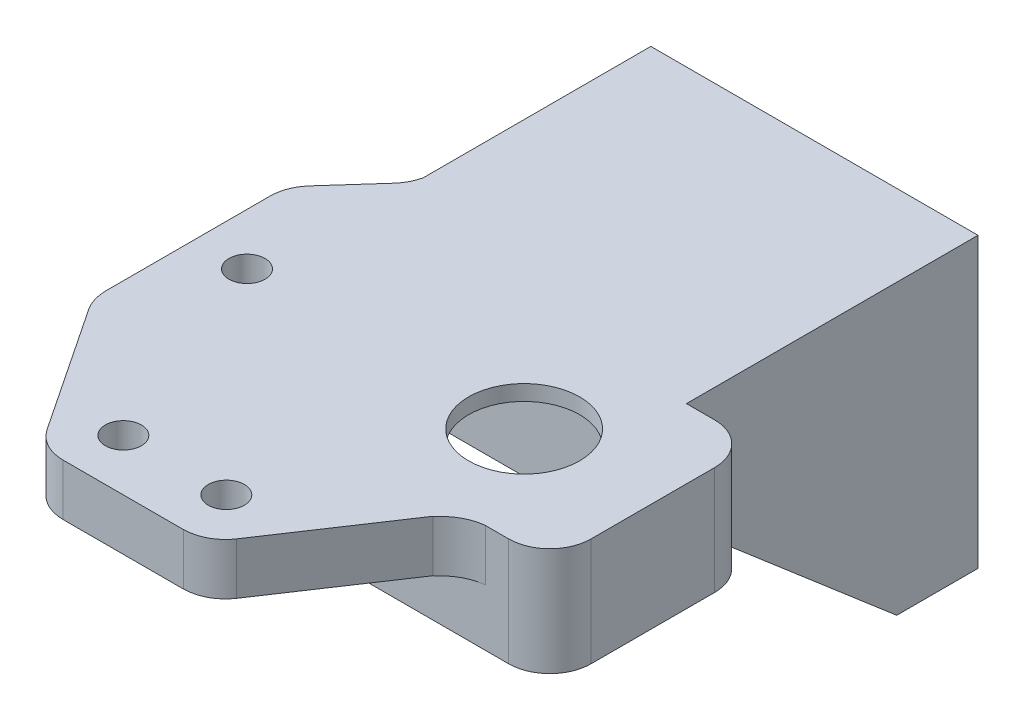
from build123d import *

# Parameters (mm, degrees)
CROQUIS2_W              = 35
CROQUIS2_H              = 20
SALIENTE_EXTRUIR1_DEPTH = 10.5
CROQUIS3_W              = 23
CROQUIS3_H              = 13
CORTAR_EXTRUIR1_DEPTH   = 9
CROQUIS4_R              = 1
CORTAR_EXTRUIR2_DEPTH   = 4
CROQUIS5_R              = 5.386
CORTAR_EXTRUIR3_DEPTH   = 4
REDONDEO1_R             = 4
SALIENTE_EXTRUIR2_DEPTH = 5
CROQUIS13_W             = 23
CROQUIS13_H             = 13
CORTAR_EXTRUIR4_DEPTH   = 9
CORTAR_EXTRUIR5_REACH   = 3.5
CROQUIS14_R             = 5.386
CORTAR_EXTRUIR6_REACH   = 12.5
CROQUIS15_R             = 1.75
CROQUIS17_W             = 28.298517207
CROQUIS17_H             = 28
SALIENTE_EXTRUIR5_DEPTH = 38.5
CROQUIS18_W             = 6.74314
CROQUIS18_H             = 28.298517207
CORTAR_EXTRUIR7_DEPTH   = 38.5
CROQUIS19_W             = 25.75686
CROQUIS19_H             = 20
CORTAR_EXTRUIR8_DEPTH   = 20.5
CORTAR_EXTRUIR9_DEPTH   = 3
CROQUIS21_R             = 2.49
CROQUIS21_R_2           = 1.3
CORTAR_EXTRUIR10_DEPTH  = 5
CORTAR_EXTRUIR11_DEPTH  = 32


with BuildPart() as part:
    # Croquis2 → Saliente-Extruir1 (new body)
    with BuildSketch(Plane(origin=(0, 0, 0), x_dir=(1, 0, 0), z_dir=(0, 1, 0))):
        with Locations((1.579773814, 6.543311496)):
            Rectangle(CROQUIS2_W, CROQUIS2_H)
    extrude(amount=SALIENTE_EXTRUIR1_DEPTH)

    # Croquis3 → Cortar-Extruir1 (cut)
    with BuildSketch(Plane.XZ):
        with Locations((1.579773814, -6.543311496)):
            Rectangle(CROQUIS3_W, CROQUIS3_H)
    extrude(amount=-CORTAR_EXTRUIR1_DEPTH, mode=Mode.SUBTRACT)

    # Croquis4 → Cortar-Extruir2 (cut)
    with BuildSketch(Plane.XZ):
        with Locations((-12.220226186, -6.543311496)):
            Circle(CROQUIS4_R)
        with Locations((15.379773814, -6.543311496)):
            Circle(CROQUIS4_R)
    extrude(amount=-CORTAR_EXTRUIR2_DEPTH, mode=Mode.SUBTRACT)

    # Croquis5 → Cortar-Extruir3 (cut)
    with BuildSketch(Plane.XZ.offset(-9)):
        with Locations((6.579773814, -6.543311496)):
            Circle(CROQUIS5_R)
    extrude(amount=-CORTAR_EXTRUIR3_DEPTH, mode=Mode.SUBTRACT)

    # Redondeo1
    redondeo1_edges = [part.edges().sort_by_distance(p)[0] for p in [
        (-15.920226186, 5.25, -16.543311496),
        (19.079773814, 5.25, -16.543311496),
        (19.079773814, 5.25, 3.456688504),
        (-15.920226186, 5.25, 3.456688504),
    ]]
    fillet(redondeo1_edges, radius=REDONDEO1_R)

    # Croquis9 → Saliente-Extruir2 (add)
    with BuildSketch(Plane(origin=(0, 10.5, 0), x_dir=(1, 0, 0), z_dir=(0, 1, 0))):
        with BuildLine():
            Line((15.079773814, 16.543311496), (12.336633814, 16.543311496))
            add(Edge.make_bspline(
                [(12.336633814, 16.543311496), (10.698610232, 16.587808838), (9.508613814, 17.714311496)],
                knots=[0, 0, 0, 1, 1, 1], degree=2))
            Line((9.508613814, 17.714311496), (1.852613814, 25.371311496))
            add(Edge.make_bspline(
                [(1.852613814, 25.371311496), (0.662441449, 26.497382931), (-0.975386186, 26.543311496)],
                knots=[0, 0, 0, 1, 1, 1], degree=2))
            Line((-0.975386186, 26.543311496), (-19.318386186, 26.543311496))
            Line((-19.318386186, 26.543311496), (-19.318386186, 23.599311496))
            add(Edge.make_bspline(
                [(-19.318386186, 23.599311496), (-19.358098596, 22.086435901), (-20.338226186, 20.933311496)],
                knots=[0, 0, 0, 1, 1, 1], degree=2))
            Line((-20.338226186, 20.933311496), (-24.301226186, 16.502311496))
            add(Edge.make_bspline(
                [(-24.301226186, 16.502311496), (-25.282063001, 15.348930114), (-25.320226186, 13.835311496)],
                knots=[0, 0, 0, 1, 1, 1], degree=2))
            Line((-25.320226186, 13.835311496), (-25.320226186, -2.244688504))
            add(Edge.make_bspline(
                [(-25.320226186, -2.244688504), (-25.287234994, -3.456650155), (-24.649226186, -4.462688504)],
                knots=[0, 0, 0, 1, 1, 1], degree=2))
            Line((-24.649226186, -4.462688504), (-16.509226186, -16.674688504))
            add(Edge.make_bspline(
                [(-16.509226186, -16.674688504), (-15.292510612, -18.399803974), (-13.182226186, -18.456688504)],
                knots=[0, 0, 0, 1, 1, 1], degree=2))
            Line((-13.182226186, -18.456688504), (-1.464226186, -18.456688504))
            add(Edge.make_bspline(
                [(-1.464226186, -18.456688504), (0.665129481, -18.357989688), (1.862773814, -16.674688504)],
                knots=[0, 0, 0, 1, 1, 1], degree=2))
            Line((1.862773814, -16.674688504), (9.492773814, -5.237688504))
            add(Edge.make_bspline(
                [(9.492773814, -5.237688504), (10.98314296, -3.636391936), (12.820773814, -3.456688504)],
                knots=[0, 0, 0, 0.39653843, 0.39653843, 0.39653843], degree=2))
            Line((12.820773814, -3.456688504), (15.079773814, -3.456688504))
            add(Edge.make_bspline(
                [(15.079773814, -3.456688504), (18.736628063, -3.113542754), (19.079773814, 0.543311496)],
                knots=[0, 0, 0, 1, 1, 1], degree=2))
            Line((19.079773814, 0.543311496), (19.079773814, 12.543311496))
            add(Edge.make_bspline(
                [(15.079773814, 16.543311496), (18.736628063, 16.200165745), (19.079773814, 12.543311496)],
                knots=[0, 0, 0, 1, 1, 1], degree=2))
        make_face()
    extrude(amount=-SALIENTE_EXTRUIR2_DEPTH)

    # Croquis13 → Cortar-Extruir4 (cut)
    with BuildSketch(Plane.XZ):
        with Locations((1.579773814, -6.543311496)):
            Rectangle(CROQUIS13_W, CROQUIS13_H)
    extrude(amount=-CORTAR_EXTRUIR4_DEPTH, mode=Mode.SUBTRACT)

    # Croquis14 → Cortar-Extruir5 (cut, up to next)
    with BuildSketch(Plane.XZ.offset(-9), mode=Mode.PRIVATE) as cortar_extruir5_sk1:
        with Locations((6.579773814, -6.543311496)):
            Circle(CROQUIS14_R)
    cortar_extruir5_tool1 = extrude(cortar_extruir5_sk1.sketch, amount=-CORTAR_EXTRUIR5_REACH, mode=Mode.PRIVATE) & part.part
    add(cortar_extruir5_tool1.solids().sort_by_distance((6.579774, 9, -6.543311))[0], mode=Mode.SUBTRACT)

    # Croquis15 → Cortar-Extruir6 (cut, up to next)
    with BuildSketch(Plane(origin=(0, 10.5, 0), x_dir=(1, 0, 0), z_dir=(0, 1, 0)), mode=Mode.PRIVATE) as cortar_extruir6_sk1:
        with Locations((-20.320226186, 6.544311496)):
            Circle(CROQUIS15_R)
    cortar_extruir6_tool1 = extrude(cortar_extruir6_sk1.sketch, amount=-CORTAR_EXTRUIR6_REACH, mode=Mode.PRIVATE) & part.part
    add(cortar_extruir6_tool1.solids().sort_by_distance((-20.320226, 10.5, -6.544311))[0], mode=Mode.SUBTRACT)
    # Croquis15 → Cortar-Extruir6 (cut, up to next)
    with BuildSketch(Plane(origin=(0, 10.5, 0), x_dir=(1, 0, 0), z_dir=(0, 1, 0)), mode=Mode.PRIVATE) as cortar_extruir6_sk2:
        with Locations((-12.324304765, -13.453196841)):
            Circle(CROQUIS15_R)
    cortar_extruir6_tool2 = extrude(cortar_extruir6_sk2.sketch, amount=-CORTAR_EXTRUIR6_REACH, mode=Mode.PRIVATE) & part.part
    add(cortar_extruir6_tool2.solids().sort_by_distance((-12.324305, 10.5, 13.453197))[0], mode=Mode.SUBTRACT)
    # Croquis15 → Cortar-Extruir6 (cut, up to next)
    with BuildSketch(Plane(origin=(0, 10.5, 0), x_dir=(1, 0, 0), z_dir=(0, 1, 0)), mode=Mode.PRIVATE) as cortar_extruir6_sk3:
        with Locations((-2.324305375, -13.456688504)):
            Circle(CROQUIS15_R)
    cortar_extruir6_tool3 = extrude(cortar_extruir6_sk3.sketch, amount=-CORTAR_EXTRUIR6_REACH, mode=Mode.PRIVATE) & part.part
    add(cortar_extruir6_tool3.solids().sort_by_distance((-2.324305, 10.5, 13.456689))[0], mode=Mode.SUBTRACT)

    # Croquis17 → Saliente-Extruir5 (add)
    with BuildSketch(Plane(origin=(19.079773814, 0, 0), x_dir=(0, 0, -1), z_dir=(1, 0, 0))):
        with Locations((30.6925701, -3.5)):
            Rectangle(CROQUIS17_W, CROQUIS17_H)
    extrude(amount=-SALIENTE_EXTRUIR5_DEPTH)

    # Croquis18 → Cortar-Extruir7 (cut)
    with BuildSketch(Plane(origin=(0, 10.5, 0), x_dir=(1, 0, 0), z_dir=(0, 1, 0))):
        with Locations((15.708203814, 30.6925701)):
            Rectangle(CROQUIS18_W, CROQUIS18_H)
    extrude(amount=-CORTAR_EXTRUIR7_DEPTH, mode=Mode.SUBTRACT)

    # Croquis19 → Cortar-Extruir8 (cut)
    with BuildSketch(Plane.XY.offset(-16.543311496)):
        with Locations((-3.541796186, -7.5)):
            Rectangle(CROQUIS19_W, CROQUIS19_H)
    extrude(amount=-CORTAR_EXTRUIR8_DEPTH, mode=Mode.SUBTRACT)

    # Croquis20 → Cortar-Extruir9 (cut)
    with BuildSketch(Plane.XY.offset(-37.043311496)):
        with BuildLine():
            Line((-7.041796186, -2.5), (-0.041796186, -2.5))
            ThreePointArc((-0.041796186, -2.5), (3.458203814, -6), (-0.041796186, -9.5))
            Line((-0.041796186, -9.5), (-7.041796186, -9.5))
            ThreePointArc((-7.041796186, -9.5), (-10.541796186, -6), (-7.041796186, -2.5))
        make_face()
    extrude(amount=-CORTAR_EXTRUIR9_DEPTH, mode=Mode.SUBTRACT)

    # Croquis21 → Cortar-Extruir10 (cut)
    with BuildSketch(Plane.XY.offset(-40.043311496)):
        with Locations((-3.541796186, -6)):
            Circle(CROQUIS21_R)
        with Locations((-8.041796186, -6)):
            Circle(CROQUIS21_R_2)
        with Locations((0.958203814, -6)):
            Circle(CROQUIS21_R_2)
    extrude(amount=-CORTAR_EXTRUIR10_DEPTH, mode=Mode.SUBTRACT)

    # Croquis22 → Cortar-Extruir11 (cut)
    with BuildSketch(Plane(origin=(12.336633814, 0, 0), x_dir=(0, 0, -1), z_dir=(1, 0, 0))):
        Polygon((16.543311496, 0), (36.954350191, -17.5), (16.543311496, -17.5), align=None)
    extrude(amount=-CORTAR_EXTRUIR11_DEPTH, mode=Mode.SUBTRACT)


solid = part.part
